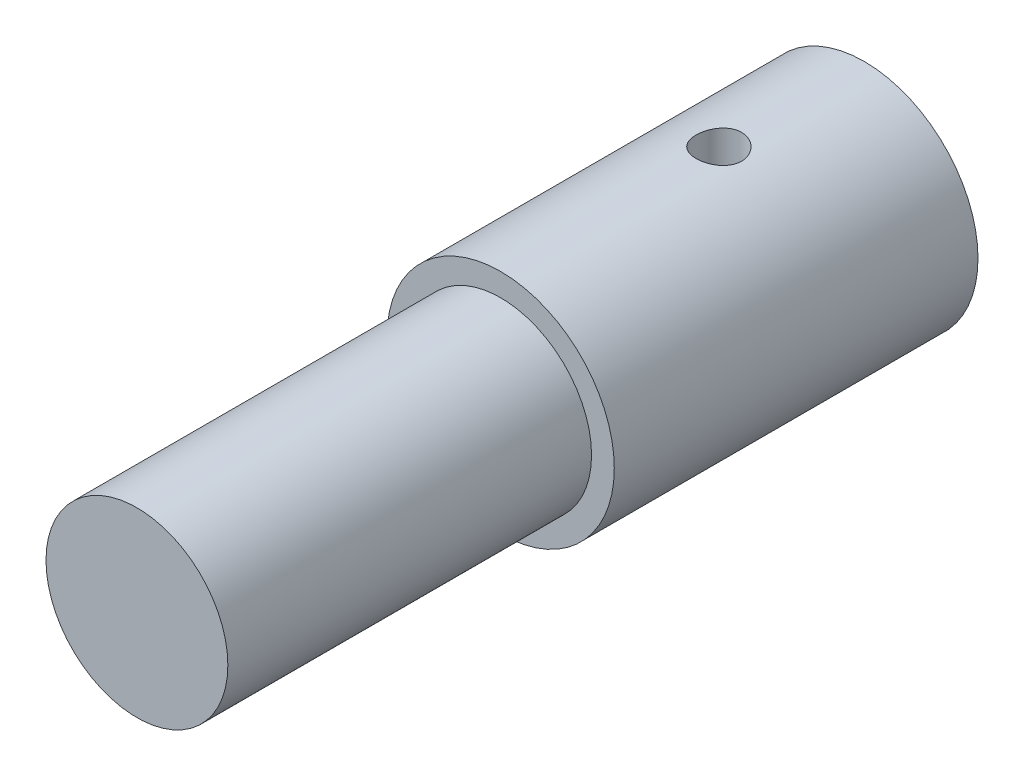
from build123d import *

# Parameters (mm, degrees)
SKETCH1_R           = 3.175
BOSS_EXTRUDE1_DEPTH = 12.7
SKETCH3_R           = 3.96875
BOSS_EXTRUDE2_DEPTH = 12.7
SKETCH4_R           = 1.5875
CUT_EXTRUDE2_DEPTH  = 8.89
SKETCH5_R           = 0.79375
CUT_EXTRUDE3_DEPTH  = 4.96875


with BuildPart() as part:
    # Sketch1 → Boss-Extrude1 (new body)
    with BuildSketch(Plane.XY):
        Circle(SKETCH1_R)
    extrude(amount=BOSS_EXTRUDE1_DEPTH)

    # Sketch3 → Boss-Extrude2 (add)
    with BuildSketch(Plane(origin=(0, 0, 0), x_dir=(-1, 0, 0), z_dir=(0, 0, -1))):
        Circle(SKETCH3_R)
    extrude(amount=BOSS_EXTRUDE2_DEPTH)

    # Sketch4 → Cut-Extrude2 (cut)
    with BuildSketch(Plane(origin=(0, 0, -12.7), x_dir=(-1, 0, 0), z_dir=(0, 0, -1))):
        Circle(SKETCH4_R)
    extrude(amount=-CUT_EXTRUDE2_DEPTH, mode=Mode.SUBTRACT)

    # Sketch5 → Cut-Extrude3 (cut, through all)
    with BuildSketch(Plane(origin=(0, 0, 0), x_dir=(1, 0, 0), z_dir=(0, 1, 0))):
        with Locations((0, 7.62)):
            Circle(SKETCH5_R)
    extrude(amount=CUT_EXTRUDE3_DEPTH, mode=Mode.SUBTRACT)


solid = part.part
